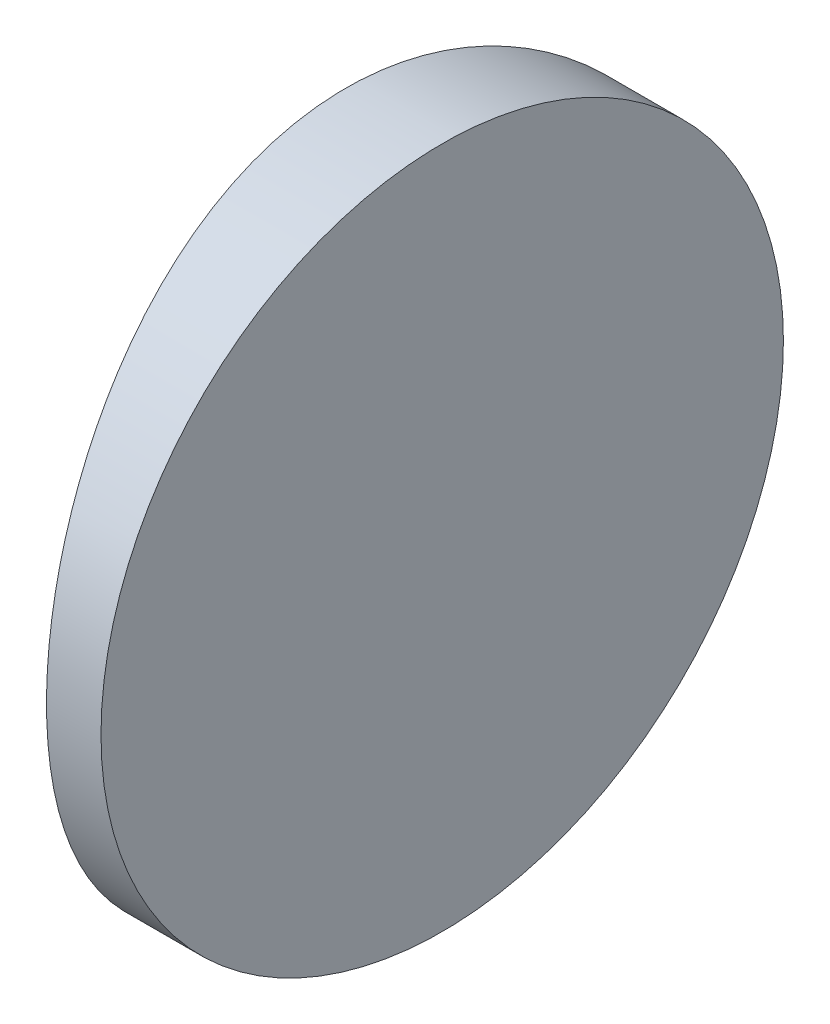
from build123d import *

# Parameters (mm, degrees)
EXTRUDE_1_DEPTH     = 25
CUT_EXTRUDE_8_DEPTH = 12.7


with BuildPart() as part:
    # 草图1 → 凸台-拉伸1 (new body)
    with BuildSketch(Plane(origin=(0, 0, 0), x_dir=(1, 0, 0), z_dir=(0, 1, 0))):
        with BuildLine():
            Line((-45.790307927, 12.5), (-43.794795665, 12.5))
            Line((-43.794795665, 12.5), (-43.794795665, -12.5))
            Line((-43.794795665, -12.5), (-45.790307927, -12.5))
            ThreePointArc((-45.790307927, -12.5), (-47.324795665, 0), (-45.790307927, 12.5))
        make_face()
    extrude(amount=EXTRUDE_1_DEPTH)

    # 草图2 → 切除-拉伸8 (cut)
    with BuildSketch(Plane(origin=(-43.794795665, 0, 0), x_dir=(0, 0, -1), z_dir=(1, 0, 0))):
        with BuildLine():
            Line((-12.5, 25), (-12.5, 12.5))
            ThreePointArc((-12.5, 12.5), (-8.838834765, 21.338834765), (0, 25))
            Line((0, 25), (-12.5, 25))
        make_face()
        with BuildLine():
            ThreePointArc((0, 25), (8.838834765, 21.338834765), (12.5, 12.5))
            Line((12.5, 12.5), (12.5, 25))
            Line((12.5, 25), (0, 25))
        make_face()
        with BuildLine():
            ThreePointArc((12.5, 12.5), (8.838834765, 3.661165235), (0, 0))
            Line((0, 0), (12.5, 0))
            Line((12.5, 0), (12.5, 12.5))
        make_face()
        with BuildLine():
            Line((-12.5, 12.5), (-12.5, 0))
            Line((-12.5, 0), (0, 0))
            ThreePointArc((0, 0), (-8.838834765, 3.661165235), (-12.5, 12.5))
        make_face()
    extrude(amount=-CUT_EXTRUDE_8_DEPTH, mode=Mode.SUBTRACT)


solid = part.part
